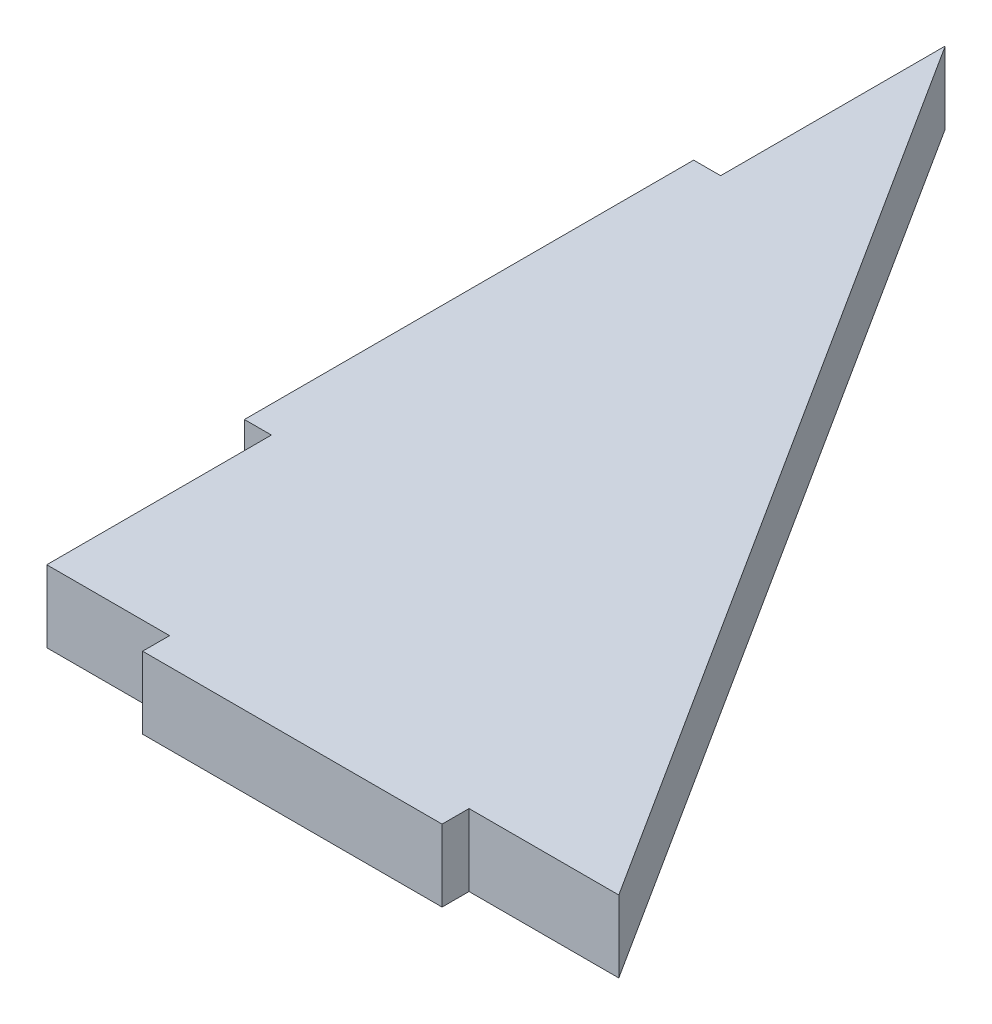
from build123d import *

# Parameters (mm, degrees)
SKETCH1_W           = 4.5
SKETCH1_H           = 75
SKETCH1_W_2         = 50
SKETCH1_H_2         = 4.5
BOSS_EXTRUDE1_DEPTH = 12


with BuildPart() as part:
    # Sketch1 → Boss-Extrude1 (new body)
    with BuildSketch(Plane(origin=(0, 0, 0), x_dir=(1, 0, 0), z_dir=(0, 1, 0))):
        with Locations((-2.25, 75)):
            Rectangle(SKETCH1_W, SKETCH1_H)
        Polygon((0, 37.5), (0, 0), (20.5, 0), (20.5, 4.5), (70.5, 4.5), (70.5, 0), (95.5, 0), (0, 150), (0, 112.5), (4.5, 112.5), (4.5, 37.5), align=None)
        with Locations((45.5, -2.25)):
            Rectangle(SKETCH1_W_2, SKETCH1_H_2)
        with Locations((45.5, 2.25)):
            Rectangle(SKETCH1_W_2, SKETCH1_H_2)
        with Locations((2.25, 75)):
            Rectangle(SKETCH1_W, SKETCH1_H)
    extrude(amount=BOSS_EXTRUDE1_DEPTH)


solid = part.part
